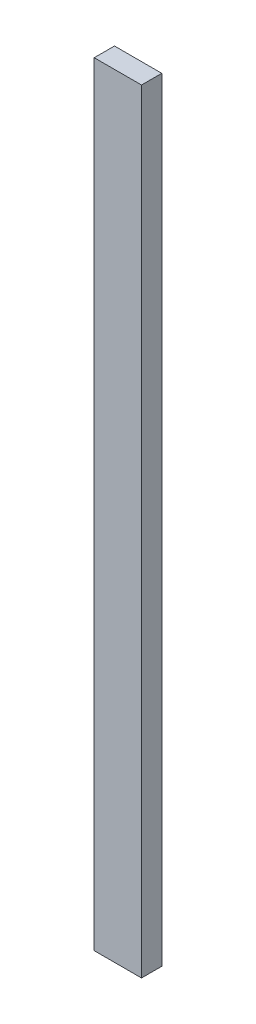
from build123d import *

# Parameters (mm, degrees)
SKETCH1_W           = 88.9
SKETCH1_H           = 38.1
BOSS_EXTRUDE1_DEPTH = 1454.15


with BuildPart() as part:
    # Sketch1 → Boss-Extrude1 (new body)
    with BuildSketch(Plane(origin=(0, 0, 0), x_dir=(1, 0, 0), z_dir=(0, 1, 0))):
        Rectangle(SKETCH1_W, SKETCH1_H)
    extrude(amount=BOSS_EXTRUDE1_DEPTH)


solid = part.part
